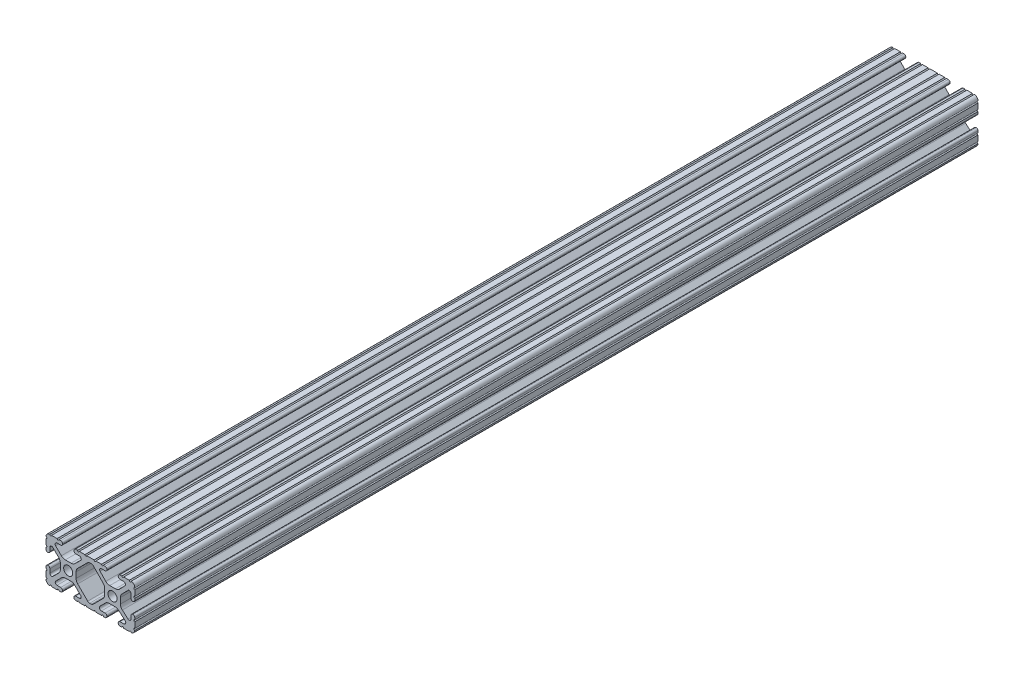
from build123d import *

# Parameters (mm, degrees)
SKETCH1_R           = 2.6035
BOSS_EXTRUDE1_DEPTH = 241.3


with BuildPart() as part:
    # Sketch1 → Boss-Extrude1 (new body, symmetric)
    with BuildSketch(Plane.XY):
        with BuildLine():
            Line((18.01710265, 12.7), (16.98745015, 12.7))
            ThreePointArc((16.98745015, 12.7), (16.245730386, 12.392769614), (15.9385, 11.65104985))
            Line((15.9385, 11.65104985), (15.9385, 11.53922))
            ThreePointArc((15.9385, 11.53922), (16.245750844, 10.797450844), (16.98752, 10.4902))
            Line((16.98752, 10.4902), (19.116384363, 10.4902))
            ThreePointArc((19.116384363, 10.4902), (20.052502933, 9.869096983), (19.844087081, 8.765172272))
            Line((19.844087081, 8.765172272), (16.618993479, 5.455112286))
            ThreePointArc((16.618993479, 5.455112286), (15.578994274, 4.745442459), (14.344932584, 4.4958))
            Line((14.344932584, 4.4958), (11.083317835, 4.4958))
            ThreePointArc((11.083317835, 4.4958), (9.854330953, 4.743306833), (8.816955189, 5.447238587))
            Line((8.816955189, 5.447238587), (5.564154119, 8.762652677))
            ThreePointArc((5.564154119, 8.762652677), (5.352591412, 9.867473037), (6.289393385, 10.4902))
            Line((6.289393385, 10.4902), (8.41248, 10.4902))
            ThreePointArc((8.41248, 10.4902), (9.154249156, 10.797450844), (9.4615, 11.53922))
            Line((9.4615, 11.53922), (9.4615, 11.65104985))
            ThreePointArc((9.4615, 11.65104985), (9.154269614, 12.392769614), (8.41254985, 12.7))
            Line((8.41254985, 12.7), (7.38288465, 12.7))
            ThreePointArc((7.38288465, 12.7), (6.87488465, 12.192), (6.36688465, 12.7))
            Line((6.36688465, 12.7), (3.14958095, 12.7))
            ThreePointArc((3.14958095, 12.7), (2.64158095, 12.192), (2.13358095, 12.7))
            Line((2.13358095, 12.7), (-2.13358095, 12.7))
            ThreePointArc((-2.13358095, 12.7), (-2.64158095, 12.192), (-3.14958095, 12.7))
            Line((-3.14958095, 12.7), (-6.36689735, 12.7))
            ThreePointArc((-6.36689735, 12.7), (-6.87489735, 12.192), (-7.38289735, 12.7))
            Line((-7.38289735, 12.7), (-8.41254985, 12.7))
            ThreePointArc((-8.41254985, 12.7), (-9.154269614, 12.392769614), (-9.4615, 11.65104985))
            Line((-9.4615, 11.65104985), (-9.4615, 11.53922))
            ThreePointArc((-9.4615, 11.53922), (-9.154249156, 10.797450844), (-8.41248, 10.4902))
            Line((-8.41248, 10.4902), (-6.283641037, 10.4902))
            ThreePointArc((-6.283641037, 10.4902), (-5.297291557, 9.829633109), (-5.532576693, 8.666071843))
            Line((-5.532576693, 8.666071843), (-8.809985098, 5.416263103))
            ThreePointArc((-8.809985098, 5.416263103), (-9.836720513, 4.734920264), (-11.045536121, 4.4958))
            Line((-11.045536121, 4.4958), (-14.354463879, 4.4958))
            ThreePointArc((-14.354463879, 4.4958), (-15.563279487, 4.734920264), (-16.590014902, 5.416263103))
            Line((-16.590014902, 5.416263103), (-19.867423307, 8.666071843))
            ThreePointArc((-19.867423307, 8.666071843), (-20.102708443, 9.829633109), (-19.116358963, 10.4902))
            Line((-19.116358963, 10.4902), (-16.98752, 10.4902))
            ThreePointArc((-16.98752, 10.4902), (-16.245750844, 10.797450844), (-15.9385, 11.53922))
            Line((-15.9385, 11.53922), (-15.9385, 11.65104985))
            ThreePointArc((-15.9385, 11.65104985), (-16.245730386, 12.392769614), (-16.98745015, 12.7))
            Line((-16.98745015, 12.7), (-18.01711535, 12.7))
            ThreePointArc((-18.01711535, 12.7), (-18.52511535, 12.192), (-19.03311535, 12.7))
            Line((-19.03311535, 12.7), (-22.2504, 12.7))
            ThreePointArc((-22.2504, 12.7), (-22.758323491, 12.192000006), (-23.266399977, 12.699846982))
            ThreePointArc((-23.266399977, 12.699846982), (-24.782522516, 12.082522516), (-25.399846982, 10.566399977))
            ThreePointArc((-25.399846982, 10.566399977), (-24.892000006, 10.058323491), (-25.4, 9.5504))
            Line((-25.4, 9.5504), (-25.4, 6.3330836))
            ThreePointArc((-25.4, 6.3330836), (-24.892, 5.8250836), (-25.4, 5.3170836))
            Line((-25.4, 5.3170836), (-25.4, 4.237520184))
            ThreePointArc((-25.4, 4.237520184), (-25.107393763, 3.531106237), (-24.400979816, 3.2385))
            Line((-24.400979816, 3.2385), (-24.23922, 3.2385))
            ThreePointArc((-24.23922, 3.2385), (-23.497450844, 3.545750844), (-23.1902, 4.28752))
            Line((-23.1902, 4.28752), (-23.1902, 6.334741132))
            ThreePointArc((-23.1902, 6.334741132), (-22.556026952, 7.286023527), (-21.434002553, 7.066535717))
            Line((-21.434002553, 7.066535717), (-18.147950853, 3.808156468))
            ThreePointArc((-18.147950853, 3.808156468), (-17.452759693, 2.774838327), (-17.208501877, 1.553619571))
            Line((-17.208501877, 1.553619571), (-17.208501877, -1.695179196))
            ThreePointArc((-17.208501877, -1.695179196), (-17.450738657, -2.911536421), (-18.140486065, -3.942289578))
            Line((-18.140486065, -3.942289578), (-21.431579576, -7.227386226))
            ThreePointArc((-21.431579576, -7.227386226), (-22.55444896, -7.449940594), (-23.1902, -6.498002195))
            Line((-23.1902, -6.498002195), (-23.1902, -4.28752))
            ThreePointArc((-23.1902, -4.28752), (-23.497450844, -3.545750844), (-24.23922, -3.2385))
            Line((-24.23922, -3.2385), (-24.35098, -3.2385))
            ThreePointArc((-24.35098, -3.2385), (-25.092749156, -3.545750844), (-25.4, -4.28752))
            Line((-25.4, -4.28752), (-25.4, -5.3171344))
            ThreePointArc((-25.4, -5.3171344), (-24.892, -5.8251344), (-25.4, -6.3331344))
            Line((-25.4, -6.3331344), (-25.4, -9.5504))
            ThreePointArc((-25.4, -9.5504), (-24.892000006, -10.058323491), (-25.399846982, -10.566399977))
            ThreePointArc((-25.399846982, -10.566399977), (-24.782522516, -12.082522516), (-23.266399977, -12.699846982))
            ThreePointArc((-23.266399977, -12.699846982), (-22.758323491, -12.192000006), (-22.2504, -12.7))
            Line((-22.2504, -12.7), (-19.03308995, -12.7))
            ThreePointArc((-19.03308995, -12.7), (-18.52508995, -12.192), (-18.01708995, -12.7))
            Line((-18.01708995, -12.7), (-16.9874692, -12.7))
            ThreePointArc((-16.9874692, -12.7), (-16.245700044, -12.392749156), (-15.9384492, -11.65098))
            Line((-15.9384492, -11.65098), (-15.9384492, -11.53922))
            ThreePointArc((-15.9384492, -11.53922), (-16.245700044, -10.797450844), (-16.9874692, -10.4902))
            Line((-16.9874692, -10.4902), (-19.116358963, -10.4902))
            ThreePointArc((-19.116358963, -10.4902), (-20.055197748, -9.862578342), (-19.834124023, -8.755124678))
            Line((-19.834124023, -8.755124678), (-16.49660751, -5.423689618))
            ThreePointArc((-16.49660751, -5.423689618), (-15.467274017, -4.736928798), (-14.253591699, -4.4958))
            Line((-14.253591699, -4.4958), (-11.146408301, -4.4958))
            ThreePointArc((-11.146408301, -4.4958), (-9.932725983, -4.736928798), (-8.90339249, -5.423689618))
            Line((-8.90339249, -5.423689618), (-5.565875977, -8.755124678))
            ThreePointArc((-5.565875977, -8.755124678), (-5.344802252, -9.862578342), (-6.283641037, -10.4902))
            Line((-6.283641037, -10.4902), (-8.4125308, -10.4902))
            ThreePointArc((-8.4125308, -10.4902), (-9.154299956, -10.797450844), (-9.4615508, -11.53922))
            Line((-9.4615508, -11.53922), (-9.4615508, -11.65098))
            ThreePointArc((-9.4615508, -11.65098), (-9.154299956, -12.392749156), (-8.4125308, -12.7))
            Line((-8.4125308, -12.7), (-7.38287195, -12.7))
            ThreePointArc((-7.38287195, -12.7), (-6.87487195, -12.192), (-6.36687195, -12.7))
            Line((-6.36687195, -12.7), (-3.14960635, -12.7))
            ThreePointArc((-3.14960635, -12.7), (-2.64160635, -12.192), (-2.13360635, -12.7))
            Line((-2.13360635, -12.7), (2.13360635, -12.7))
            ThreePointArc((2.13360635, -12.7), (2.64159365, -12.1920127), (3.14958095, -12.7))
            Line((3.14958095, -12.7), (6.36691005, -12.7))
            ThreePointArc((6.36691005, -12.7), (6.87491005, -12.192), (7.38291005, -12.7))
            Line((7.38291005, -12.7), (8.4125308, -12.7))
            ThreePointArc((8.4125308, -12.7), (9.154299956, -12.392749156), (9.4615508, -11.65098))
            Line((9.4615508, -11.65098), (9.4615508, -11.53922))
            ThreePointArc((9.4615508, -11.53922), (9.154299956, -10.797450844), (8.4125308, -10.4902))
            Line((8.4125308, -10.4902), (6.289393385, -10.4902))
            ThreePointArc((6.289393385, -10.4902), (5.231590322, -9.783049717), (5.480677245, -8.535265862))
            Line((5.480677245, -8.535265862), (8.597933595, -5.423689618))
            ThreePointArc((8.597933595, -5.423689618), (9.627267088, -4.736928798), (10.840949406, -4.4958))
            Line((10.840949406, -4.4958), (14.102564155, -4.4958))
            ThreePointArc((14.102564155, -4.4958), (15.215927525, -4.697410182), (16.187895372, -5.276636531))
            Line((16.187895372, -5.276636531), (19.868247549, -8.482246082))
            ThreePointArc((19.868247549, -8.482246082), (20.188435806, -9.746879864), (19.116384363, -10.4902))
            Line((19.116384363, -10.4902), (16.9874692, -10.4902))
            ThreePointArc((16.9874692, -10.4902), (16.245700044, -10.797450844), (15.9384492, -11.53922))
            Line((15.9384492, -11.53922), (15.9384492, -11.65098))
            ThreePointArc((15.9384492, -11.65098), (16.245700044, -12.392749156), (16.9874692, -12.7))
            Line((16.9874692, -12.7), (18.01710265, -12.7))
            ThreePointArc((18.01710265, -12.7), (18.52510265, -12.192), (19.03310265, -12.7))
            Line((19.03310265, -12.7), (22.2504, -12.7))
            ThreePointArc((22.2504, -12.7), (22.758323491, -12.192000006), (23.266399977, -12.699846982))
            ThreePointArc((23.266399977, -12.699846982), (24.782522516, -12.082522516), (25.399846982, -10.566399977))
            ThreePointArc((25.399846982, -10.566399977), (24.892000006, -10.058323492), (25.4, -9.550400001))
            Line((25.4, -9.550400001), (25.4, -6.333083592))
            ThreePointArc((25.4, -6.333083592), (24.892000001, -5.825083593), (25.4, -5.317083593))
            Line((25.4, -5.317083593), (25.4, -4.237520184))
            ThreePointArc((25.4, -4.237520184), (25.107393763, -3.531106237), (24.400979816, -3.2385))
            Line((24.400979816, -3.2385), (24.189220184, -3.2385))
            ThreePointArc((24.189220184, -3.2385), (23.482806237, -3.531106237), (23.1902, -4.237520184))
            Line((23.1902, -4.237520184), (23.1902, -6.155876159))
            ThreePointArc((23.1902, -6.155876159), (22.62232736, -7.038258539), (21.583974541, -6.886926384))
            Line((21.583974541, -6.886926384), (18.29817066, -4.024970844))
            ThreePointArc((18.29817066, -4.024970844), (17.493730985, -2.946044689), (17.208501877, -1.630807374))
            Line((17.208501877, -1.630807374), (17.208501877, 1.630807374))
            ThreePointArc((17.208501877, 1.630807374), (17.442348332, 2.82673414), (18.109440981, 3.846495088))
            Line((18.109440981, 3.846495088), (21.526346532, 7.353420386))
            ThreePointArc((21.526346532, 7.353420386), (22.585896263, 7.574939077), (23.1902, 6.676867167))
            Line((23.1902, 6.676867167), (23.1902, 4.237520184))
            ThreePointArc((23.1902, 4.237520184), (23.482806237, 3.531106237), (24.189220184, 3.2385))
            Line((24.189220184, 3.2385), (24.400979816, 3.2385))
            ThreePointArc((24.400979816, 3.2385), (25.107393763, 3.531106237), (25.4, 4.237520184))
            Line((25.4, 4.237520184), (25.4, 5.3170836))
            ThreePointArc((25.4, 5.3170836), (24.891949193, 5.825134407), (25.4, 6.333185215))
            Line((25.4, 6.333185215), (25.4, 9.550400015))
            ThreePointArc((25.4, 9.550400015), (24.892000013, 10.058323498), (25.399846982, 10.566399977))
            ThreePointArc((25.399846982, 10.566399977), (24.782522516, 12.082522516), (23.266399977, 12.699846982))
            ThreePointArc((23.266399977, 12.699846982), (22.758323491, 12.192000006), (22.2504, 12.7))
            Line((22.2504, 12.7), (19.03310265, 12.7))
            ThreePointArc((19.03310265, 12.7), (18.52510265, 12.192), (18.01710265, 12.7))
        make_face()
        with Locations((-12.7, 0)):
            Circle(SKETCH1_R, mode=Mode.SUBTRACT)
        with Locations((12.7, 0)):
            Circle(SKETCH1_R, mode=Mode.SUBTRACT)
        with BuildLine():
            Line((-7.259513935, -3.869413038), (-1.545748891, -9.572766749))
            ThreePointArc((-1.545748891, -9.572766749), (-1.035199478, -9.913400116), (-0.433213048, -10.033))
            Line((-0.433213048, -10.033), (0.433213048, -10.033))
            ThreePointArc((0.433213048, -10.033), (1.035199478, -9.913400116), (1.545748891, -9.572766749))
            Line((1.545748891, -9.572766749), (7.259513935, -3.869413038))
            ThreePointArc((7.259513935, -3.869413038), (7.949261343, -2.838659881), (8.191498123, -1.622302656))
            Line((8.191498123, -1.622302656), (8.191498123, 1.622302656))
            ThreePointArc((8.191498123, 1.622302656), (7.955573352, 2.823327967), (7.282860769, 3.845864069))
            Line((7.282860769, 3.845864069), (1.675572808, 9.561086461))
            ThreePointArc((1.675572808, 9.561086461), (1.161034429, 9.910236611), (0.551456936, 10.033))
            Line((0.551456936, 10.033), (-0.395199982, 10.033))
            ThreePointArc((-0.395199982, 10.033), (-0.994772524, 9.914396349), (-1.50403329, 9.576450301))
            Line((-1.50403329, 9.576450301), (-7.252049147, 3.876839553))
            ThreePointArc((-7.252049147, 3.876839553), (-7.947240307, 2.843521412), (-8.191498123, 1.622302656))
            Line((-8.191498123, 1.622302656), (-8.191498123, -1.622302656))
            ThreePointArc((-8.191498123, -1.622302656), (-7.949261343, -2.838659881), (-7.259513935, -3.869413038))
        make_face(mode=Mode.SUBTRACT)
    extrude(amount=BOSS_EXTRUDE1_DEPTH, both=True)


solid = part.part
